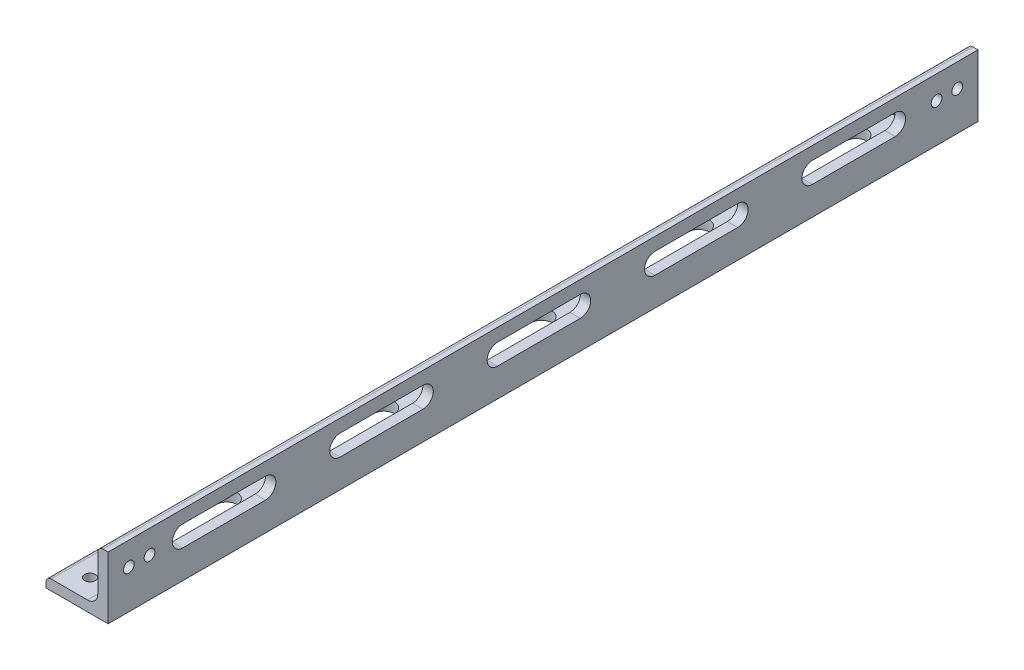
from build123d import *

# Parameters (mm, degrees)
BOSS_EXTRUDE1_DEPTH = 133.35
SKETCH3_R           = 1.651
CUT_EXTRUDE1_DEPTH  = 135.628985549
SKETCH4_R           = 1.651
CUT_EXTRUDE2_DEPTH  = 135.628985549
CUT_EXTRUDE3_DEPTH  = 135.628985549
LPATTERN1_COUNT     = 5
LPATTERN1_PITCH     = 48.26
CUT_EXTRUDE4_DEPTH  = 135.628985549
LPATTERN2_COUNT     = 5
LPATTERN2_PITCH     = 48.26


with BuildPart() as part:
    # Sketch2 → Boss-Extrude1 (new, symmetric)
    with BuildSketch(Plane.XY):
        with BuildLine():
            Line((-9.525, -9.525), (9.525, -9.525))
            Line((9.525, -9.525), (9.525, 9.525))
            Line((9.525, 9.525), (7.9375, 9.525))
            ThreePointArc((7.9375, 9.525), (6.814967985, 9.060032015), (6.35, 7.9375))
            Line((6.35, 7.9375), (6.35, -3.175))
            ThreePointArc((6.35, -3.175), (5.42006403, -5.42006403), (3.175, -6.35))
            Line((3.175, -6.35), (-7.9375, -6.35))
            ThreePointArc((-7.9375, -6.35), (-9.060032015, -6.814967985), (-9.525, -7.9375))
            Line((-9.525, -7.9375), (-9.525, -9.525))
        make_face()
    extrude(amount=BOSS_EXTRUDE1_DEPTH, both=True)

    # Sketch3 → Cut-Extrude1 (cut, through all)
    with BuildSketch(Plane(origin=(0, -6.35, 0), x_dir=(1, 0, 0), z_dir=(0, 1, 0))):
        with Locations(Location((-2.38125, 127, 0), (0, 0, 180))):
            Circle(SKETCH3_R)
        with Locations(Location((-2.38125, 120.65, 0), (0, 0, 180))):
            Circle(SKETCH3_R)
        with Locations((-2.38125, -120.65)):
            Circle(SKETCH3_R)
        with Locations((-2.38125, -127)):
            Circle(SKETCH3_R)
    extrude(amount=-CUT_EXTRUDE1_DEPTH, mode=Mode.SUBTRACT)

    # Sketch4 → Cut-Extrude2 (cut, through all)
    with BuildSketch(Plane.ZY.offset(-6.35)):
        with Locations(Location((-127, 2.381250687, 0), (0, 0, 270))):
            Circle(SKETCH4_R)
        with Locations(Location((-120.650000001, 2.381165043, 0), (0, 0, 270))):
            Circle(SKETCH4_R)
        with Locations(Location((120.650000001, 2.381165043, 0), (0, 0, 90))):
            Circle(SKETCH4_R)
        with Locations(Location((127, 2.381250687, 0), (0, 0, 90))):
            Circle(SKETCH4_R)
    extrude(amount=-CUT_EXTRUDE2_DEPTH, mode=Mode.SUBTRACT)

    # Sketch5 → Cut-Extrude3 (cut, through all)
    with BuildSketch(Plane.ZY.offset(-6.35)):
        with BuildLine():
            Line((-107.950000001, 5.556165043), (-82.550000001, 5.556165043))
            ThreePointArc((-82.550000001, 5.556165043), (-79.375000001, 2.381165043), (-82.550000001, -0.793834957))
            Line((-82.550000001, -0.793834957), (-107.950000001, -0.793834957))
            ThreePointArc((-107.950000001, -0.793834957), (-111.125000001, 2.381165043), (-107.950000001, 5.556165043))
        make_face()
    cut_extrude3 = extrude(amount=-CUT_EXTRUDE3_DEPTH, mode=Mode.SUBTRACT)

    # LPattern1: Cut-Extrude3 ×5
    with Locations(*[(0, 0, i * LPATTERN1_PITCH) for i in range(1, LPATTERN1_COUNT)]):
        add(cut_extrude3, mode=Mode.SUBTRACT)

    # Sketch6 → Cut-Extrude4 (cut, through all)
    with BuildSketch(Plane(origin=(0, -6.35, 0), x_dir=(1, 0, 0), z_dir=(0, 1, 0))):
        with BuildLine():
            Line((-5.55625, 107.95), (-5.55625, 82.55))
            ThreePointArc((-5.55625, 82.55), (-2.38125, 79.375), (0.79375, 82.55))
            Line((0.79375, 82.55), (0.79375, 107.95))
            ThreePointArc((0.79375, 107.95), (-2.38125, 111.125), (-5.55625, 107.95))
        make_face()
    cut_extrude4 = extrude(amount=-CUT_EXTRUDE4_DEPTH, mode=Mode.SUBTRACT)

    # LPattern2: Cut-Extrude4 ×5
    with Locations(*[(0, 0, i * LPATTERN2_PITCH) for i in range(1, LPATTERN2_COUNT)]):
        add(cut_extrude4, mode=Mode.SUBTRACT)


solid = part.part
